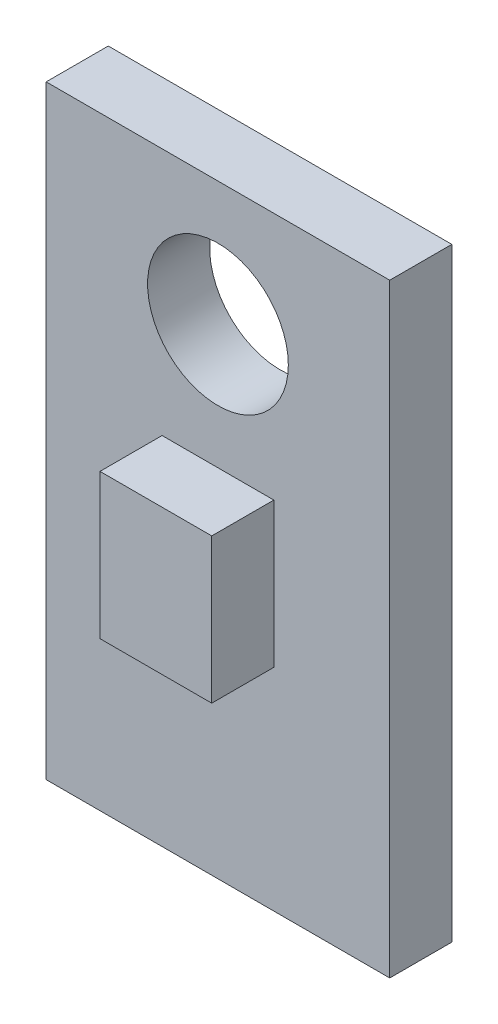
from build123d import *

# Parameters (mm, degrees)
SKETCH1_W           = 8.3
SKETCH1_H           = 14.6
BOSS_EXTRUDE1_DEPTH = 1.5
SKETCH2_R           = 1.7
CUT_EXTRUDE1_DEPTH  = 1.5
SKETCH3_W           = 2.7
SKETCH3_H           = 3.5
BOSS_EXTRUDE3_DEPTH = 1.5


with BuildPart() as part:
    # Sketch1 → Boss-Extrude1 (new body)
    with BuildSketch(Plane.XY):
        with Locations((4.15, 7.3)):
            Rectangle(SKETCH1_W, SKETCH1_H)
    extrude(amount=BOSS_EXTRUDE1_DEPTH)

    # Sketch2 → Cut-Extrude1 (cut)
    with BuildSketch(Plane.XY.offset(1.5)):
        with Locations((4.15, 11.6)):
            Circle(SKETCH2_R)
    extrude(amount=-CUT_EXTRUDE1_DEPTH, mode=Mode.SUBTRACT)

    # Sketch3 → Boss-Extrude3 (add)
    with BuildSketch(Plane.XY.offset(1.5)):
        with Locations((4.15, 6.85)):
            Rectangle(SKETCH3_W, SKETCH3_H)
    extrude(amount=BOSS_EXTRUDE3_DEPTH)


solid = part.part
